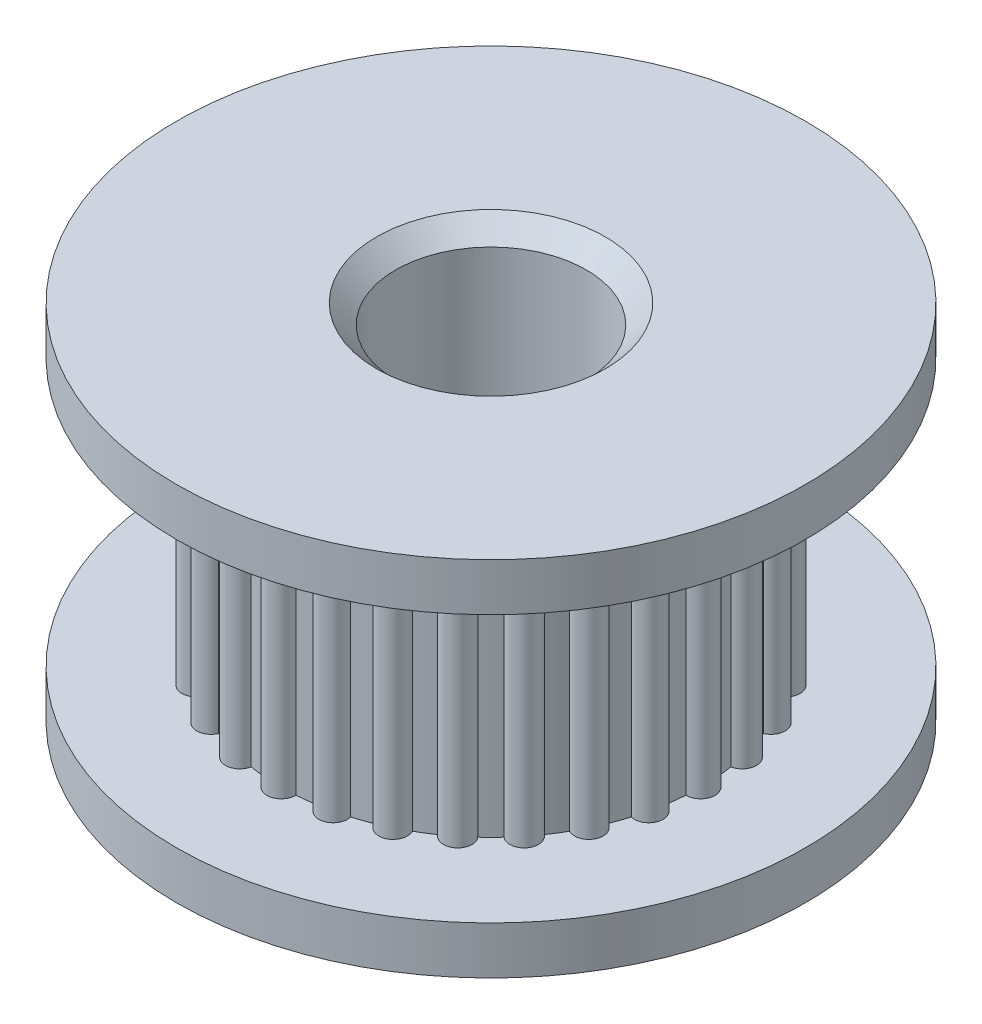
from build123d import *

# Parameters (mm, degrees)
SKETCH1_R               = 8.382
BOSS_EXTRUDE1_DEPTH     = 1.27
SKETCH2_R               = 5.588
BOSS_EXTRUDE2_DEPTH     = 7.112
SKETCH3_R               = 8.382
BOSS_EXTRUDE3_DEPTH     = 1.27
SKETCH4_R               = 2.54
CUT_EXTRUDE1_DEPTH      = 1
CUT_EXTRUDE1_DEPTH_BACK = 10.652
CHAMFER1_SIZE           = 0.508


with BuildPart() as part:
    # Sketch1 → Boss-Extrude1 (new body)
    with BuildSketch(Plane(origin=(0, 0, 0), x_dir=(1, 0, 0), z_dir=(0, 1, 0))):
        Circle(SKETCH1_R)
    extrude(amount=-BOSS_EXTRUDE1_DEPTH)

    # Sketch2 → Boss-Extrude2 (add)
    with BuildSketch(Plane(origin=(0, 0, 0), x_dir=(1, 0, 0), z_dir=(0, 1, 0))):
        with BuildLine():
            ThreePointArc((-4.121307864, 3.77366738), (-4.666752119, 3.721610627), (-4.596130935, 3.178258081))
            ThreePointArc((-4.596130935, 3.178258081), (-4.368874324, 3.484061013), (-4.121307864, 3.77366738))
        make_face()
        with BuildLine():
            ThreePointArc((-4.857698061, 2.761976385), (-5.377883173, 2.589852039), (-5.188125293, 2.075837167))
            ThreePointArc((-5.188125293, 2.075837167), (-5.034614034, 2.424542334), (-4.857698061, 2.761976385))
        make_face()
        with BuildLine():
            ThreePointArc((-5.350502993, 1.611788361), (-5.819344708, 1.328227455), (-5.519965385, 0.86932511))
            ThreePointArc((-5.519965385, 0.86932511), (-5.447897173, 1.243446979), (-5.350502993, 1.611788361))
        make_face()
        with BuildLine():
            ThreePointArc((-5.575011364, 0.380778538), (-5.969, 0), (-5.575011364, -0.380778538))
            ThreePointArc((-5.575011364, -0.380778538), (-5.588, 0), (-5.575011364, 0.380778538))
        make_face()
        with BuildLine():
            ThreePointArc((-5.350502993, -1.611788361), (-5.447897173, -1.243446979), (-5.519965385, -0.86932511))
            ThreePointArc((-5.519965385, -0.86932511), (-5.819344708, -1.328227455), (-5.350502993, -1.611788361))
        make_face()
        with BuildLine():
            ThreePointArc((-4.857698061, -2.761976385), (-5.034614034, -2.424542334), (-5.188125293, -2.075837167))
            ThreePointArc((-5.188125293, -2.075837167), (-5.377883173, -2.589852039), (-4.857698061, -2.761976385))
        make_face()
        with BuildLine():
            ThreePointArc((-4.121307864, -3.77366738), (-4.368874324, -3.484061013), (-4.596130935, -3.178258081))
            ThreePointArc((-4.596130935, -3.178258081), (-4.666752119, -3.721610627), (-4.121307864, -3.77366738))
        make_face()
        with BuildLine():
            ThreePointArc((-2.075837167, -5.188125293), (-2.424542334, -5.034614034), (-2.761976385, -4.857698061))
            ThreePointArc((-2.761976385, -4.857698061), (-2.589852039, -5.377883173), (-2.075837167, -5.188125293))
        make_face()
        with BuildLine():
            ThreePointArc((-0.86932511, -5.519965385), (-1.243446979, -5.447897173), (-1.611788361, -5.350502993))
            ThreePointArc((-1.611788361, -5.350502993), (-1.328227455, -5.819344708), (-0.86932511, -5.519965385))
        make_face()
        with BuildLine():
            ThreePointArc((2.761976385, -4.857698061), (2.424542334, -5.034614034), (2.075837167, -5.188125293))
            ThreePointArc((2.075837167, -5.188125293), (2.589852039, -5.377883173), (2.761976385, -4.857698061))
        make_face()
        with BuildLine():
            ThreePointArc((3.77366738, -4.121307864), (3.484061013, -4.368874324), (3.178258081, -4.596130935))
            ThreePointArc((3.178258081, -4.596130935), (3.721610627, -4.666752119), (3.77366738, -4.121307864))
        make_face()
        with BuildLine():
            ThreePointArc((4.596130935, -3.178258081), (4.368874324, -3.484061013), (4.121307864, -3.77366738))
            ThreePointArc((4.121307864, -3.77366738), (4.666752119, -3.721610627), (4.596130935, -3.178258081))
        make_face()
        with BuildLine():
            ThreePointArc((5.188125293, -2.075837167), (5.034614034, -2.424542334), (4.857698061, -2.761976385))
            ThreePointArc((4.857698061, -2.761976385), (5.377883173, -2.589852039), (5.188125293, -2.075837167))
        make_face()
        with BuildLine():
            ThreePointArc((5.588, 0), (5.584751897, -0.1905), (5.575011364, -0.380778538))
            ThreePointArc((5.575011364, -0.380778538), (5.969, 0), (5.575011364, 0.380778538))
            ThreePointArc((5.575011364, 0.380778538), (5.584751897, 0.1905), (5.588, 0))
        make_face()
        with BuildLine():
            ThreePointArc((5.519965385, 0.86932511), (5.819344708, 1.328227455), (5.350502993, 1.611788361))
            ThreePointArc((5.350502993, 1.611788361), (5.447897173, 1.243446979), (5.519965385, 0.86932511))
        make_face()
        with BuildLine():
            ThreePointArc((5.188125293, 2.075837167), (5.377883173, 2.589852039), (4.857698061, 2.761976385))
            ThreePointArc((4.857698061, 2.761976385), (5.034614034, 2.424542334), (5.188125293, 2.075837167))
        make_face()
        with BuildLine():
            ThreePointArc((4.596130935, 3.178258081), (4.666752119, 3.721610627), (4.121307864, 3.77366738))
            ThreePointArc((4.121307864, 3.77366738), (4.368874324, 3.484061013), (4.596130935, 3.178258081))
        make_face()
        with BuildLine():
            ThreePointArc((3.77366738, 4.121307864), (3.721610627, 4.666752119), (3.178258081, 4.596130935))
            ThreePointArc((3.178258081, 4.596130935), (3.484061013, 4.368874324), (3.77366738, 4.121307864))
        make_face()
        with BuildLine():
            ThreePointArc((2.761976385, 4.857698061), (2.589852039, 5.377883173), (2.075837167, 5.188125293))
            ThreePointArc((2.075837167, 5.188125293), (2.424542334, 5.034614034), (2.761976385, 4.857698061))
        make_face()
        with BuildLine():
            ThreePointArc((1.611788361, 5.350502993), (1.328227455, 5.819344708), (0.86932511, 5.519965385))
            ThreePointArc((0.86932511, 5.519965385), (1.243446979, 5.447897173), (1.611788361, 5.350502993))
        make_face()
        with BuildLine():
            ThreePointArc((0.380778538, 5.575011364), (0, 5.969), (-0.380778538, 5.575011364))
            ThreePointArc((-0.380778538, 5.575011364), (0, 5.588), (0.380778538, 5.575011364))
        make_face()
        with BuildLine():
            ThreePointArc((-0.86932511, 5.519965385), (-1.328227455, 5.819344708), (-1.611788361, 5.350502993))
            ThreePointArc((-1.611788361, 5.350502993), (-1.243446979, 5.447897173), (-0.86932511, 5.519965385))
        make_face()
        with BuildLine():
            ThreePointArc((-2.075837167, 5.188125293), (-2.589852039, 5.377883173), (-2.761976385, 4.857698061))
            ThreePointArc((-2.761976385, 4.857698061), (-2.424542334, 5.034614034), (-2.075837167, 5.188125293))
        make_face()
        with BuildLine():
            ThreePointArc((-3.178258081, 4.596130935), (-3.721610627, 4.666752119), (-3.77366738, 4.121307864))
            ThreePointArc((-3.77366738, 4.121307864), (-3.484061013, 4.368874324), (-3.178258081, 4.596130935))
        make_face()
        with BuildLine():
            ThreePointArc((-3.178258081, -4.596130935), (-3.484061013, -4.368874324), (-3.77366738, -4.121307864))
            ThreePointArc((-3.77366738, -4.121307864), (-3.721610627, -4.666752119), (-3.178258081, -4.596130935))
        make_face()
        with BuildLine():
            ThreePointArc((0.380778538, -5.575011364), (0, -5.588), (-0.380778538, -5.575011364))
            ThreePointArc((-0.380778538, -5.575011364), (0, -5.969), (0.380778538, -5.575011364))
        make_face()
        with BuildLine():
            ThreePointArc((1.611788361, -5.350502993), (1.243446979, -5.447897173), (0.86932511, -5.519965385))
            ThreePointArc((0.86932511, -5.519965385), (1.328227455, -5.819344708), (1.611788361, -5.350502993))
        make_face()
        with BuildLine():
            ThreePointArc((5.519965385, -0.86932511), (5.447897173, -1.243446979), (5.350502993, -1.611788361))
            ThreePointArc((5.350502993, -1.611788361), (5.819344708, -1.328227455), (5.519965385, -0.86932511))
        make_face()
        Circle(SKETCH2_R)
    extrude(amount=BOSS_EXTRUDE2_DEPTH)

    # Sketch3 → Boss-Extrude3 (add)
    with BuildSketch(Plane(origin=(0, 7.112, 0), x_dir=(1, 0, 0), z_dir=(0, 1, 0))):
        Circle(SKETCH3_R)
    extrude(amount=BOSS_EXTRUDE3_DEPTH)

    # Sketch4 → Cut-Extrude1 (cut, two sides)
    with BuildSketch(Plane.XZ.offset(1.27)) as cut_extrude1_sk:
        Circle(SKETCH4_R)
    extrude(amount=CUT_EXTRUDE1_DEPTH, mode=Mode.SUBTRACT)
    extrude(cut_extrude1_sk.sketch, amount=-CUT_EXTRUDE1_DEPTH_BACK, mode=Mode.SUBTRACT)

    # Chamfer1
    chamfer1_edges = [part.edges().sort_by_distance(p)[0] for p in [
        (-2.54, 8.382, 0),
        (-2.54, -1.27, 0),
    ]]
    chamfer(chamfer1_edges, length=CHAMFER1_SIZE)


solid = part.part
